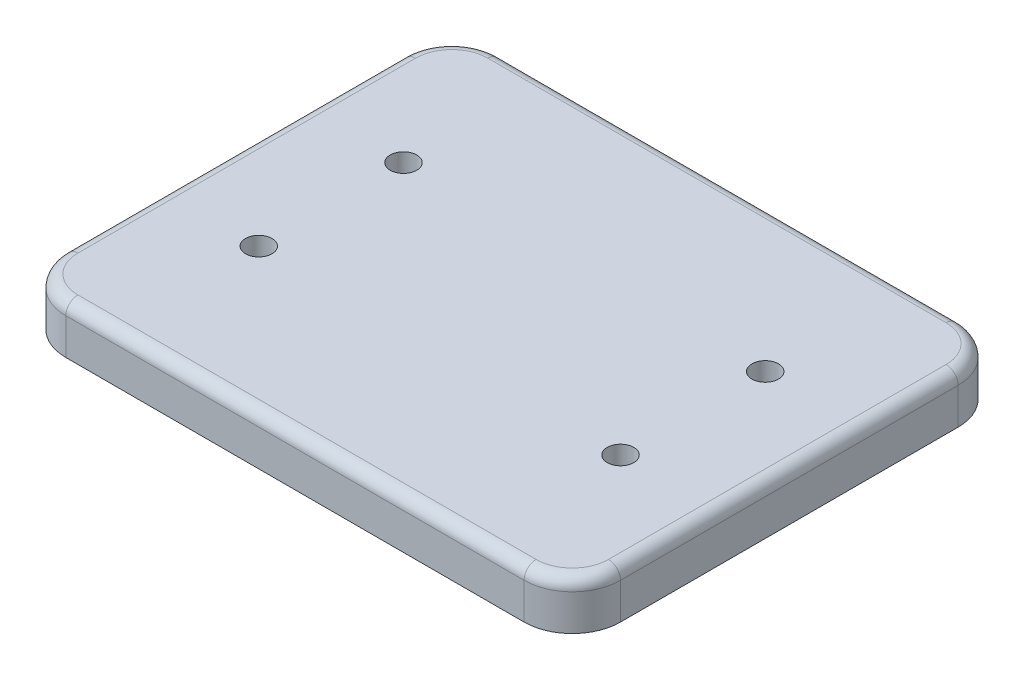
from build123d import *

# Parameters (mm, degrees)
BOSS_EXTRUDE1_DEPTH = 20
FILLET1_R           = 5
SKETCH2_R           = 5.5
CUT_EXTRUDE1_DEPTH  = 21
SKETCH4_R           = 9
CUT_EXTRUDE2_DEPTH  = 11


with BuildPart() as part:
    # Sketch1 → Boss-Extrude1 (new body)
    with BuildSketch(Plane(origin=(0, 0, 0), x_dir=(1, 0, 0), z_dir=(0, 1, 0))):
        with BuildLine():
            Line((-95, -90), (95, -90))
            ThreePointArc((95, -90), (109.142135624, -84.142135624), (115, -70))
            Line((115, -70), (115, 70))
            ThreePointArc((115, 70), (109.142135624, 84.142135624), (95, 90))
            Line((95, 90), (-95, 90))
            ThreePointArc((-95, 90), (-109.142135624, 84.142135624), (-115, 70))
            Line((-115, 70), (-115, -70))
            ThreePointArc((-115, -70), (-109.142135624, -84.142135624), (-95, -90))
        make_face()
    extrude(amount=BOSS_EXTRUDE1_DEPTH)

    # Fillet1
    fillet1_edges = [part.edges().sort_by_distance(p)[0] for p in [
        (109.142135624, 20, -84.142135624),
        (0, 20, -90),
        (-109.142135624, 20, -84.142135624),
        (-115, 20, 0),
        (-109.142135624, 20, 84.142135624),
        (0, 20, 90),
        (109.142135624, 20, 84.142135624),
        (115, 20, 0),
    ]]
    fillet(fillet1_edges, radius=FILLET1_R)

    # Sketch2 → Cut-Extrude1 (cut, through all)
    with BuildSketch(Plane(origin=(0, 20, 0), x_dir=(1, 0, 0), z_dir=(0, 1, 0))):
        with Locations((-75, 30)):
            Circle(SKETCH2_R)
        with Locations((75, 30)):
            Circle(SKETCH2_R)
    cut_extrude1 = extrude(amount=-CUT_EXTRUDE1_DEPTH, mode=Mode.SUBTRACT)

    # Sketch4 → Cut-Extrude2 (cut)
    with BuildSketch(Plane.XZ):
        with Locations((-75, -30)):
            Circle(SKETCH4_R)
        with Locations((75, -30)):
            Circle(SKETCH4_R)
    cut_extrude2 = extrude(amount=-CUT_EXTRUDE2_DEPTH, mode=Mode.SUBTRACT)

    # Mirror1: Cut-Extrude1, Cut-Extrude2 across plane
    add(cut_extrude1.mirror(Plane.XY), mode=Mode.SUBTRACT)
    add(cut_extrude2.mirror(Plane.XY), mode=Mode.SUBTRACT)


solid = part.part
